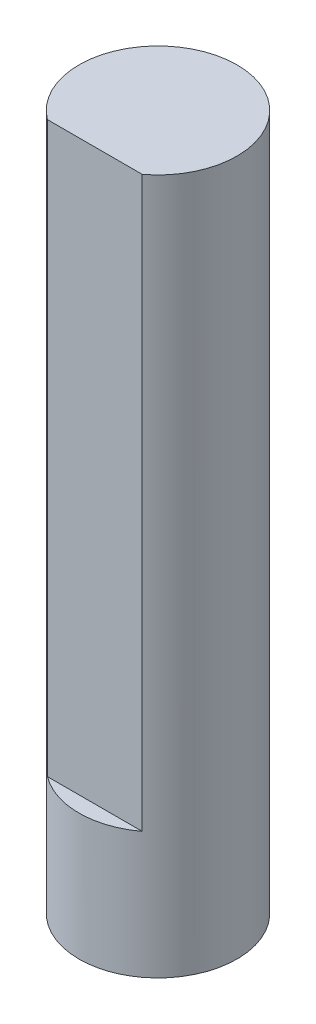
from build123d import *

# Parameters (mm, degrees)
SKETCH_1_R          = 2.5
EXTRUDE_1_DEPTH     = 22
SKETCH_2_W          = 5
SKETCH_2_H          = 18
CUT_EXTRUDE_1_DEPTH = 0.5


with BuildPart() as part:
    # 草图1 → 凸台-拉伸1 (new body)
    with BuildSketch(Plane(origin=(0, 0, 0), x_dir=(1, 0, 0), z_dir=(0, 1, 0))):
        Circle(SKETCH_1_R)
    extrude(amount=EXTRUDE_1_DEPTH)

    # 草图2 → 切除-拉伸1 (cut)
    with BuildSketch(Plane.XY.offset(2.5)):
        with Locations((0, 13)):
            Rectangle(SKETCH_2_W, SKETCH_2_H)
    extrude(amount=-CUT_EXTRUDE_1_DEPTH, mode=Mode.SUBTRACT)


solid = part.part
